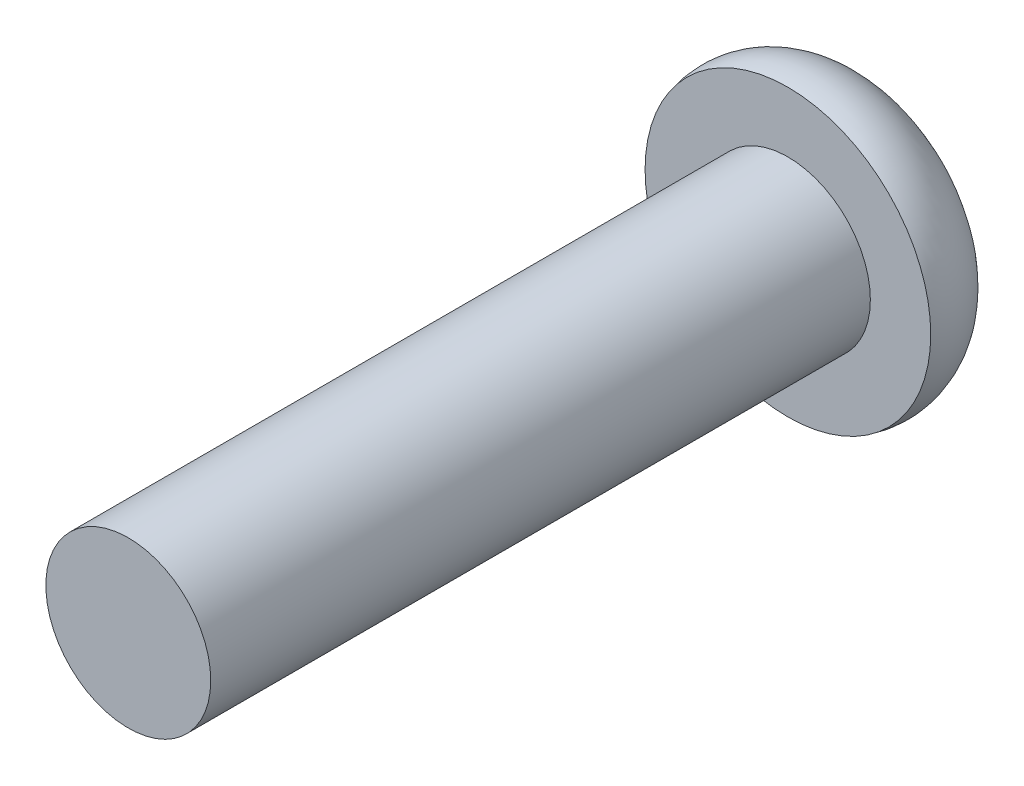
from build123d import *

# Parameters (mm, degrees)
CUT_EXTRUDE1_DEPTH = 3.25


with BuildPart() as part:
    # Sketch1 → Revolve1 (revolve)
    with BuildSketch(Plane(origin=(0, 0, 0), x_dir=(1, 0, 0), z_dir=(0, 1, 0))):
        with BuildLine():
            Line((0, 0), (-3.175, 0))
            Line((-3.175, 0), (-3.175, 25.4))
            Line((-3.175, 25.4), (-5.5, 25.4))
            ThreePointArc((-5.5, 25.4), (-5.050152433, 27.640501872), (-3, 28.65))
            Line((-3, 28.65), (0, 28.65))
            Line((0, 28.65), (0, 0))
        make_face()
    revolve(axis=Axis((0, 0, 0), (0, 0, -1)))

    # Sketch2 → Cut-Extrude1 (cut)
    with BuildSketch(Plane(origin=(0, 0, -28.65), x_dir=(-1, 0, 0), z_dir=(0, 0, -1))):
        Polygon((0, -2.309401077), (2, -1.154700538), (2, 1.154700538), (0, 2.309401077), (-2, 1.154700538), (-2, -1.154700538), align=None)
    extrude(amount=-CUT_EXTRUDE1_DEPTH, mode=Mode.SUBTRACT)


solid = part.part
